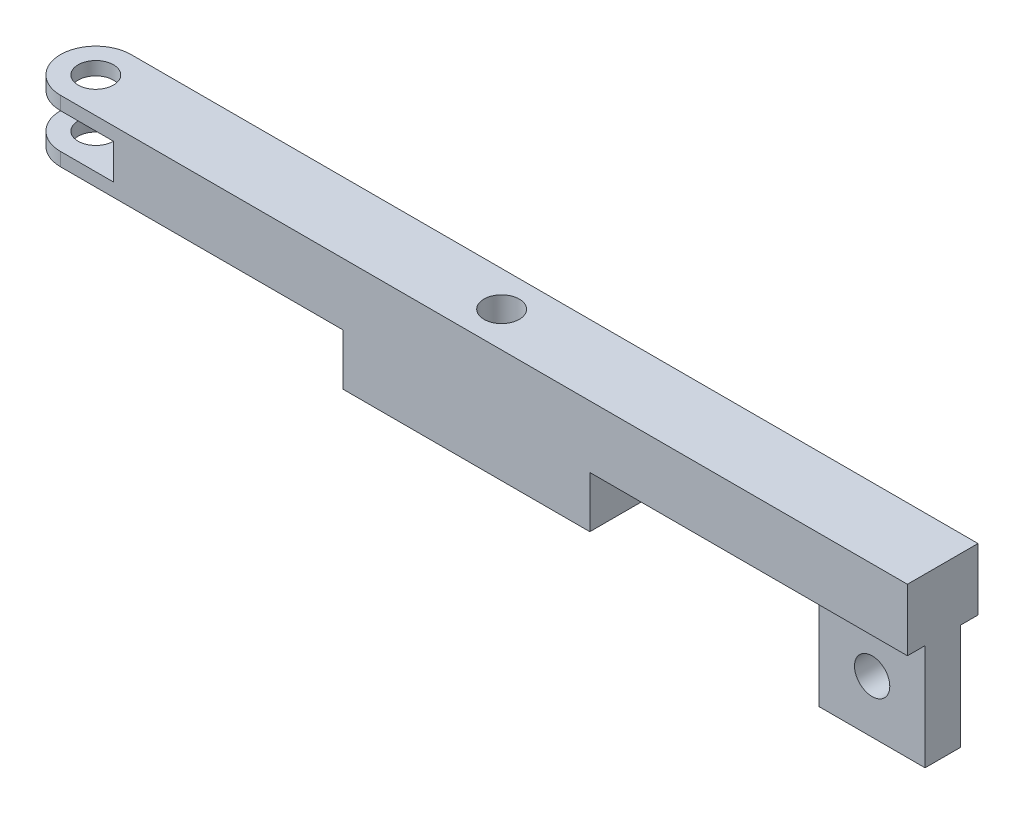
from build123d import *

# Parameters (mm, degrees)
BOSS_EXTRUDE1_DEPTH = 20
SKETCH2_R           = 5
CUT_EXTRUDE1_DEPTH  = 20
SKETCH3_W           = 70
SKETCH3_H           = 20
SKETCH3_R           = 5
BOSS_EXTRUDE2_DEPTH = 14.55
SKETCH4_W           = 30
SKETCH4_H           = 10
BOSS_EXTRUDE3_DEPTH = 30
SKETCH5_R           = 5
CUT_EXTRUDE2_DEPTH  = 20


with BuildPart() as part:
    # Sketch1 → Boss-Extrude1 (new body)
    with BuildSketch(Plane.XY):
        Polygon((-125, -8.78), (125, -8.78), (125, 8.78), (-125, 8.78), (-125, 5), (-100, 5), (-100, -5), (-125, -5), align=None)
    extrude(amount=BOSS_EXTRUDE1_DEPTH)

    # Sketch2 → Cut-Extrude1 (cut, symmetric)
    with BuildSketch(Plane.XZ.offset(-5)):
        with Locations((-115, 10)):
            Circle(SKETCH2_R)
        with Locations((0, 10)):
            Circle(SKETCH2_R)
        with BuildLine():
            Line((-115, 20), (-115, 22.029141536))
            Line((-115, 22.029141536), (-130, 22.029141536))
            Line((-130, 22.029141536), (-130, -2.19309391))
            Line((-130, -2.19309391), (-115, -2.19309391))
            Line((-115, -2.19309391), (-115, 0))
            ThreePointArc((-115, 0), (-125, 10), (-115, 20))
        make_face()
    extrude(amount=CUT_EXTRUDE1_DEPTH, both=True, mode=Mode.SUBTRACT)

    # Sketch3 → Boss-Extrude2 (add)
    with BuildSketch(Plane.XZ.offset(8.78)):
        with Locations((0, 10)):
            Rectangle(SKETCH3_W, SKETCH3_H)
        with Locations((0, 10)):
            Circle(SKETCH3_R, mode=Mode.SUBTRACT)
    extrude(amount=BOSS_EXTRUDE2_DEPTH)

    # Sketch4 → Boss-Extrude3 (add)
    with BuildSketch(Plane.XZ.offset(8.78)):
        with Locations((110, 10)):
            Rectangle(SKETCH4_W, SKETCH4_H)
    extrude(amount=BOSS_EXTRUDE3_DEPTH)

    # Sketch5 → Cut-Extrude2 (cut)
    with BuildSketch(Plane.XY.offset(15)):
        with Locations((110, -23.78)):
            Circle(SKETCH5_R)
    extrude(amount=-CUT_EXTRUDE2_DEPTH, mode=Mode.SUBTRACT)


solid = part.part
